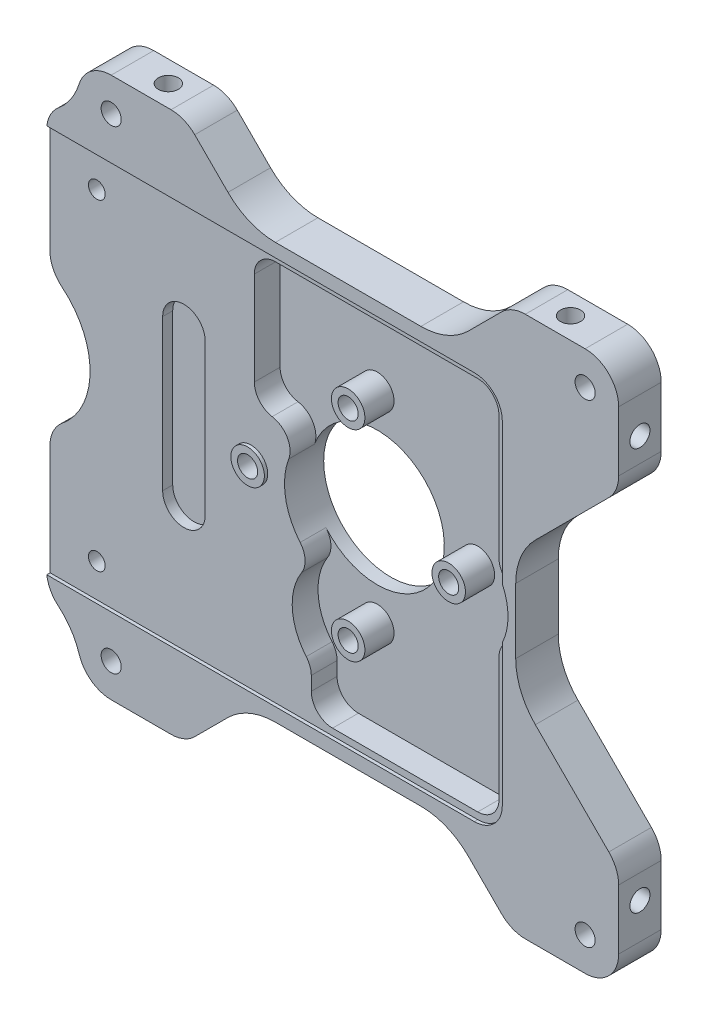
from build123d import *

# Parameters (mm, degrees)
SKETCH1_W                 = 85.355339059
SKETCH1_H                 = 80.710678118
BOSS_EXTRUDE1_DEPTH       = 6.35
CUT_EXTRUDE1_DEPTH        = 0.5
CUT_EXTRUDE2_DEPTH        = 3.85
SKETCH4_W                 = 68
SKETCH4_H                 = 0.5
CUT_EXTRUDE3_DEPTH        = 1
SKETCH5_W                 = 68
SKETCH5_H                 = 0.5
CUT_EXTRUDE4_DEPTH        = 1
CUT_EXTRUDE5_DEPTH        = 7.35
SKETCH7_W                 = 30
SKETCH7_H                 = 9.355339059
CUT_EXTRUDE6_DEPTH        = 7.35
SKETCH8_W                 = 15.355339059
SKETCH8_H                 = 18
CUT_EXTRUDE7_DEPTH        = 7.35
CUT_EXTRUDE8_DEPTH        = 7.35
SKETCH10_W                = 30
SKETCH10_H                = 9.355339059
CUT_EXTRUDE9_DEPTH        = 7.35
CUT_EXTRUDE10_DEPTH       = 6.85
CUT_EXTRUDE11_DEPTH       = 1.5
DRAFT1_ANGLE              = 45
DRAFT2_ANGLE              = 45
DRAFT3_ANGLE              = 45
SKETCH13_W                = 10
SKETCH13_H                = 5.85
SKETCH14_W                = 2.5
SKETCH14_H                = 4.35
SKETCH15_W                = 2.5
SKETCH15_H                = 4.35
SKETCH16_W                = 2.5
SKETCH16_H                = 4.35
SKETCH17_W                = 2.5
SKETCH17_H                = 0.5
F_2_CLEARANCE_HOLE1_D     = 2.5
F_2_CLEARANCE_HOLE1_DEPTH = 6.35
F_3_CLEARANCE_HOLE1_D     = 3
F_3_CLEARANCE_HOLE1_DEPTH = 6.35
F_3_CLEARANCE_HOLE2_D     = 3
F_3_CLEARANCE_HOLE2_DEPTH = 6.35
F_3_CLEARANCE_HOLE3_D     = 3
F_3_CLEARANCE_HOLE3_DEPTH = 12
F_3_CLEARANCE_HOLE4_D     = 3
F_3_CLEARANCE_HOLE4_DEPTH = 12
F_3_CLEARANCE_HOLE5_D     = 3
F_3_CLEARANCE_HOLE5_DEPTH = 8
FILLET1_R                 = 3.175
FILLET2_R                 = 4.175
FILLET3_R                 = 5
FILLET4_R                 = 10


with BuildPart() as part:
    # Sketch1 → Boss-Extrude1 (new body)
    with BuildSketch(Plane.XY.offset(6.35)):
        with Locations((58.00266953, 0)):
            Rectangle(SKETCH1_W, SKETCH1_H)
    extrude(amount=-BOSS_EXTRUDE1_DEPTH)

    # Sketch2 → Cut-Extrude1 (cut)
    with BuildSketch(Plane.XY.offset(6.35)):
        with BuildLine():
            Line((15.325, -28), (83.325, -28))
            Line((83.325, -28), (83.325, -3.784507895))
            ThreePointArc((83.325, -3.784507895), (84.175, 0), (83.325, 3.784507894))
            Line((83.325, 3.784507894), (83.325, 28))
            Line((83.325, 28), (15.325, 28))
            Line((15.325, 28), (15.325, -28))
        make_face()
    extrude(amount=-CUT_EXTRUDE1_DEPTH, mode=Mode.SUBTRACT)

    # Sketch3 → Cut-Extrude2 (cut)
    with BuildSketch(Plane.XY.offset(5.85)):
        with BuildLine():
            Line((82.325, 5.415025392), (82.325, 28))
            Line((82.325, 28), (45.825, 28))
            Line((45.825, 28), (45.825, 10.874857598))
            ThreePointArc((45.825, 10.874857598), (46.581622253, 8.817657055), (48.490873433, 7.740943889))
            ThreePointArc((48.490873433, 7.740943889), (50.727145491, 6.201837814), (50.956306919, 3.4967971))
            ThreePointArc((50.956306919, 3.4967971), (69.866260129, 2.994053299), (54.63385571, -8.222583333))
            ThreePointArc((54.63385571, -8.222583333), (51.477391425, -14.794275673), (54.325, -21.505574533))
            Line((54.325, -21.505574533), (54.325, -28))
            Line((54.325, -28), (82.325, -28))
            Line((82.325, -28), (82.325, -5.415025392))
            ThreePointArc((82.325, -5.415025392), (84.175, 0), (82.325, 5.415025392))
        make_face()
    extrude(amount=-CUT_EXTRUDE2_DEPTH, mode=Mode.SUBTRACT)

    # Sketch4 → Cut-Extrude3 (cut)
    with BuildSketch(Plane.XZ.offset(-28)):
        with Locations((49.325, 6.1)):
            Rectangle(SKETCH4_W, SKETCH4_H)
    extrude(amount=-CUT_EXTRUDE3_DEPTH, mode=Mode.SUBTRACT)

    # Sketch5 → Cut-Extrude4 (cut)
    with BuildSketch(Plane(origin=(0, -28, 0), x_dir=(-1, 0, 0), z_dir=(0, 1, 0))):
        with Locations((-49.325, 6.1)):
            Rectangle(SKETCH5_W, SKETCH5_H)
    extrude(amount=-CUT_EXTRUDE4_DEPTH, mode=Mode.SUBTRACT)

    # Sketch6 → Cut-Extrude5 (cut, through all)
    with BuildSketch(Plane.XY.offset(6.35)):
        with BuildLine():
            Line((20.643770546, 40.355339059), (15.325, 40.355339059))
            Line((15.325, 40.355339059), (15.325, 31))
            ThreePointArc((15.325, 31), (19.350148184, 34.901195315), (20.643770546, 40.355339059))
        make_face()
    extrude(amount=-CUT_EXTRUDE5_DEPTH, mode=Mode.SUBTRACT)

    # Sketch7 → Cut-Extrude6 (cut, through all)
    with BuildSketch(Plane.XY.offset(6.35)):
        with Locations((60.325, 35.67766953)):
            Rectangle(SKETCH7_W, SKETCH7_H)
    extrude(amount=-CUT_EXTRUDE6_DEPTH, mode=Mode.SUBTRACT)

    # Sketch8 → Cut-Extrude7 (cut, through all)
    with BuildSketch(Plane.XY.offset(6.35)):
        with Locations((93.002669529, 0)):
            Rectangle(SKETCH8_W, SKETCH8_H)
    extrude(amount=-CUT_EXTRUDE7_DEPTH, mode=Mode.SUBTRACT)

    # Sketch9 → Cut-Extrude8 (cut, through all)
    with BuildSketch(Plane.XY.offset(6.35)):
        with BuildLine():
            Line((15.325, -31), (15.325, -40.355339059))
            Line((15.325, -40.355339059), (20.643770546, -40.355339059))
            ThreePointArc((20.643770546, -40.355339059), (19.350148184, -34.901195315), (15.325, -31))
        make_face()
    extrude(amount=-CUT_EXTRUDE8_DEPTH, mode=Mode.SUBTRACT)

    # Sketch10 → Cut-Extrude9 (cut, through all)
    with BuildSketch(Plane.XY.offset(6.35)):
        with Locations((60.325, -35.67766953)):
            Rectangle(SKETCH10_W, SKETCH10_H)
    extrude(amount=-CUT_EXTRUDE9_DEPTH, mode=Mode.SUBTRACT)

    # Sketch11 → Cut-Extrude10 (cut, through all)
    with BuildSketch(Plane.XY.offset(5.85)):
        with BuildLine():
            Line((15.325, 10), (15.325, -10))
            ThreePointArc((15.325, -10), (21.325, 0), (15.325, 10))
        make_face()
    extrude(amount=-CUT_EXTRUDE10_DEPTH, mode=Mode.SUBTRACT)

    # Sketch12 → Cut-Extrude11 (cut)
    with BuildSketch(Plane.XY.offset(5.85)):
        with BuildLine():
            Line((32.150000014, 12.5), (32.150000014, -10))
            ThreePointArc((32.150000014, -10), (35.325000015, -13.175000001), (38.500000016, -10))
            Line((38.500000016, -10), (38.500000016, 12.5))
            ThreePointArc((38.500000016, 12.5), (35.325000015, 15.675000001), (32.150000014, 12.5))
        make_face()
    extrude(amount=-CUT_EXTRUDE11_DEPTH, mode=Mode.SUBTRACT)

    # Draft1
    draft1_faces = [part.faces().sort_by_distance(p)[0] for p in [
        (45.325, 35.677669529, 3.175),
        (75.325, 35.677669529, 3.175),
    ]]
    draft(draft1_faces, Plane(origin=(45.325, 31, 0), x_dir=(1, 0, 0), z_dir=(0, 1, 0)), DRAFT1_ANGLE)

    # Draft2
    draft2_faces = [part.faces().sort_by_distance(p)[0] for p in [
        (45.325, -35.67766953, 3.175),
        (75.325, -35.677669529, 3.175),
    ]]
    draft(draft2_faces, Plane(origin=(75.325, -31, 0), x_dir=(0, 0, -1), z_dir=(0, -1, 0)), DRAFT2_ANGLE)

    # Draft3
    draft3_faces = [part.faces().sort_by_distance(p)[0] for p in [
        (93.002669529, 9, 3.175),
        (93.002669529, -9, 3.175),
    ]]
    draft(draft3_faces, Plane(origin=(85.325, 9, 0), x_dir=(0, 0, 1), z_dir=(1, 0, 0)), DRAFT3_ANGLE)

    # Sketch13 → Cut-Revolve1 (revolve, cut)
    with BuildSketch(Plane.XZ):
        with Locations((65.325, 2.925)):
            Rectangle(SKETCH13_W, SKETCH13_H)
    revolve(axis=Axis((60.325, 0, 5.85), (0, 0, -1)), mode=Mode.SUBTRACT)

    # Sketch14 → Revolve1 (revolve)
    with BuildSketch(Plane.XZ.offset(-15)):
        with Locations((61.575, 4.175)):
            Rectangle(SKETCH14_W, SKETCH14_H)
    revolve(axis=Axis((60.325, 15, 6.35), (0, 0, -1)))

    # Sketch15 → Revolve2 (revolve)
    with BuildSketch(Plane.XZ):
        with Locations((76.575, 4.175)):
            Rectangle(SKETCH15_W, SKETCH15_H)
    revolve(axis=Axis((75.325, 0, 6.35), (0, 0, -1)))

    # Sketch16 → Revolve3 (revolve)
    with BuildSketch(Plane.XZ.offset(15)):
        with Locations((61.575, 4.175)):
            Rectangle(SKETCH16_W, SKETCH16_H)
    revolve(axis=Axis((60.325, -15, 6.35), (0, 0, -1)))

    # Sketch17 → Revolve4 (revolve)
    with BuildSketch(Plane(origin=(0, 0, 0), x_dir=(1, 0, 0), z_dir=(0, 1, 0))):
        with Locations((46.575, -6.1)):
            Rectangle(SKETCH17_W, SKETCH17_H)
    revolve(axis=Axis((45.325, 0, 5.85), (0, 0, 1)))

    # #2 Clearance Hole1
    with Locations(Plane(origin=(0, 0, 0), x_dir=(-1, 0, 0), z_dir=(0, 0, -1))):
        with Locations((-22.325, -24), (-22.325, 24)):
            Hole(F_2_CLEARANCE_HOLE1_D / 2, depth=F_2_CLEARANCE_HOLE1_DEPTH)

    # #3 Clearance Hole1
    with Locations(Plane.XY.offset(6.35)):
        with Locations((45.325, 0), (60.325, 15), (75.325, 0), (60.325, -15)):
            Hole(F_3_CLEARANCE_HOLE1_D / 2, depth=F_3_CLEARANCE_HOLE1_DEPTH)

    # #3 Clearance Hole2
    with Locations(Plane(origin=(0, 0, 0), x_dir=(-1, 0, 0), z_dir=(0, 0, -1))):
        with Locations((-24.969660941, 35.355339059), (-95.680339059, 35.355339059), (-95.680339059, -35.355339059), (-24.969660941, -35.355339059)):
            Hole(F_3_CLEARANCE_HOLE2_D / 2, depth=F_3_CLEARANCE_HOLE2_DEPTH)

    # #3 Clearance Hole3
    with Locations(Plane(origin=(0, -40.355339059, 0), x_dir=(-1, 0, 0), z_dir=(0, -1, 0))):
        with Locations((-30.325, -3.175), (-90.325, -3.175)):
            Hole(F_3_CLEARANCE_HOLE3_D / 2, depth=F_3_CLEARANCE_HOLE3_DEPTH)

    # #3 Clearance Hole4
    with Locations(Plane(origin=(0, 40.355339059, 0), x_dir=(1, 0, 0), z_dir=(0, 1, 0))):
        with Locations((90.325, -3.175), (30.325, -3.175)):
            Hole(F_3_CLEARANCE_HOLE4_D / 2, depth=F_3_CLEARANCE_HOLE4_DEPTH)

    # #3 Clearance Hole5
    with Locations(Plane(origin=(100.680339059, 0, 0), x_dir=(0, 0, -1), z_dir=(1, 0, 0))):
        with Locations((-3.175, -30), (-3.175, 30)):
            Hole(F_3_CLEARANCE_HOLE5_D / 2, depth=F_3_CLEARANCE_HOLE5_DEPTH)

    # Fillet1
    fillet1_edges = [part.edges().sort_by_distance(p)[0] for p in [
        (82.325, 5.415025392, 3.925),
        (82.325, -5.415025392, 3.925),
        (82.325, -28, 3.925),
        (54.325, -28, 3.925),
        (54.325, -21.505574533, 3.925),
        (54.63385571, -8.222583333, 3.925),
        (45.825, 28, 3.925),
        (82.325, 28, 3.925),
    ]]
    fillet(fillet1_edges, radius=FILLET1_R)

    # Fillet2
    fillet2_edges = [part.edges().sort_by_distance(p)[0] for p in [
        (83.325, 29, 6.1),
        (83.325, -29, 6.1),
    ]]
    fillet(fillet2_edges, radius=FILLET2_R)

    # Fillet3
    fillet3_edges = [part.edges().sort_by_distance(p)[0] for p in [
        (35.969660941, -40.355339059, 3.175),
        (84.680339059, 40.355339059, 3.175),
        (100.680339059, 40.355339059, 3.175),
        (100.680339059, -24.355339059, 3.175),
        (15.325, 10, 2.925),
        (15.325, -10, 2.925),
        (100.680339059, 24.355339059, 3.175),
        (100.680339059, -40.355339059, 3.175),
        (35.969660941, 40.355339059, 3.175),
        (84.680339059, -40.355339059, 3.175),
        (20.643770546, 40.355339059, 3.175),
        (15.325, 31, 3.175),
        (15.325, -31, 3.175),
        (20.643770546, -40.355339059, 3.175),
    ]]
    fillet(fillet3_edges, radius=FILLET3_R)

    # Fillet4
    fillet4_edges = [part.edges().sort_by_distance(p)[0] for p in [
        (75.325, 31, 3.175),
        (45.325, 31, 3.175),
        (85.325, -9, 3.175),
        (85.325, 9, 3.175),
        (45.325, -31, 3.175),
        (75.325, -31, 3.175),
    ]]
    fillet(fillet4_edges, radius=FILLET4_R)


solid = part.part
